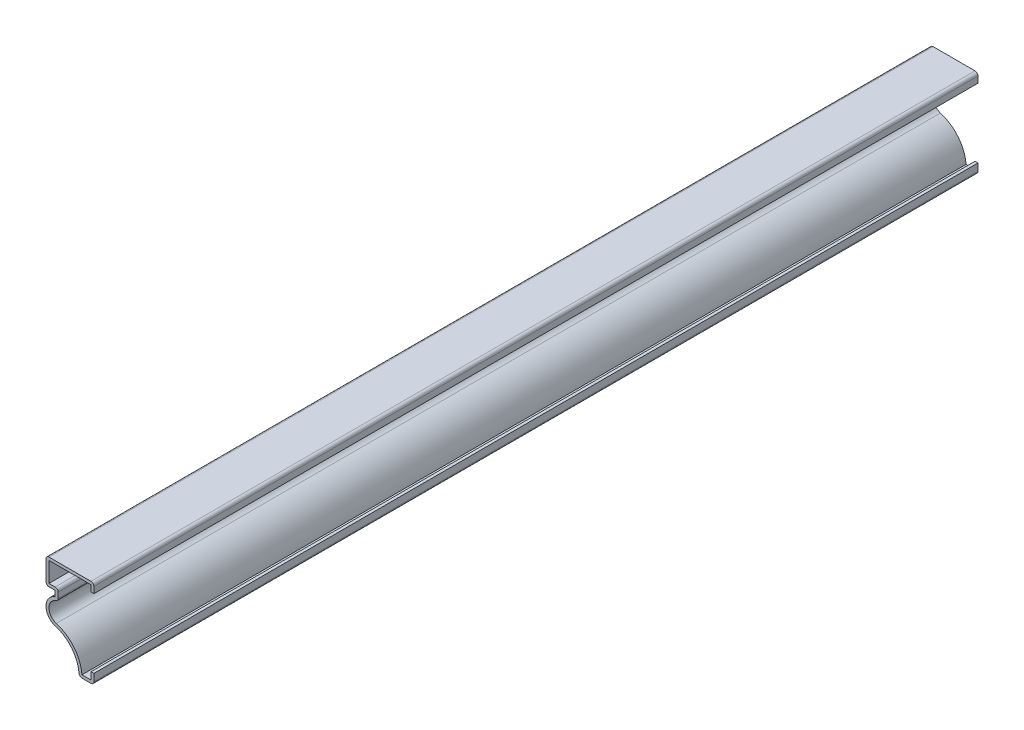
from build123d import *

# Parameters (mm, degrees)
EXTRUDE_THIN1_DEPTH = 381
FILLET1_R           = 1.27


with BuildPart() as part:
    # Sketch1 → Extrude-Thin1 (new body)
    with BuildSketch(Plane.XY):
        with BuildLine():
            Line((0, 34.13125), (0, 38.1))
            Line((0, 38.1), (-20.6375, 38.1))
            Line((-20.6375, 38.1), (-20.6375, 26.9875))
            Line((-20.6375, 26.9875), (-16.66875, 26.9875))
            Line((-16.66875, 26.9875), (-16.66875, 24.60625))
            ThreePointArc((-16.66875, 24.60625), (-20.637199415, 19.108011605), (-16.556782099, 13.692348143))
            ThreePointArc((-16.556782099, 13.692348143), (-9.182459335, 8.539010459), (-6.35, 0))
            Line((-6.35, 0), (0, 0))
            Line((0, 0), (0, 4.365625))
            Line((0, 4.365625), (-1.27, 4.365625))
            Line((-1.27, 4.365625), (-1.27, 1.27))
            Line((-1.27, 1.27), (-5.131923382, 1.27))
            ThreePointArc((-5.131923382, 1.27), (-8.5544739, 9.799810535), (-16.194051619, 14.909445755))
            ThreePointArc((-16.194051619, 14.909445755), (-19.348945082, 19.572203738), (-15.39875, 23.58351569))
            Line((-15.39875, 23.58351569), (-15.39875, 28.2575))
            Line((-15.39875, 28.2575), (-19.3675, 28.2575))
            Line((-19.3675, 28.2575), (-19.3675, 36.83))
            Line((-19.3675, 36.83), (-1.27, 36.83))
            Line((-1.27, 36.83), (-1.27, 34.13125))
            Line((-1.27, 34.13125), (0, 34.13125))
        make_face()
    extrude(amount=-EXTRUDE_THIN1_DEPTH)

    # Fillet1
    fillet1_edges = [part.edges().sort_by_distance(p)[0] for p in [
        (0, 0, -190.5),
        (-6.35, 0, -190.5),
        (-20.6375, 26.9875, -190.5),
        (-20.6375, 38.1, -190.5),
        (0, 38.1, -190.5),
        (-15.39875, 28.2575, -190.5),
        (-15.39875, 23.58351569, -190.5),
    ]]
    fillet(fillet1_edges, radius=FILLET1_R)


solid = part.part
